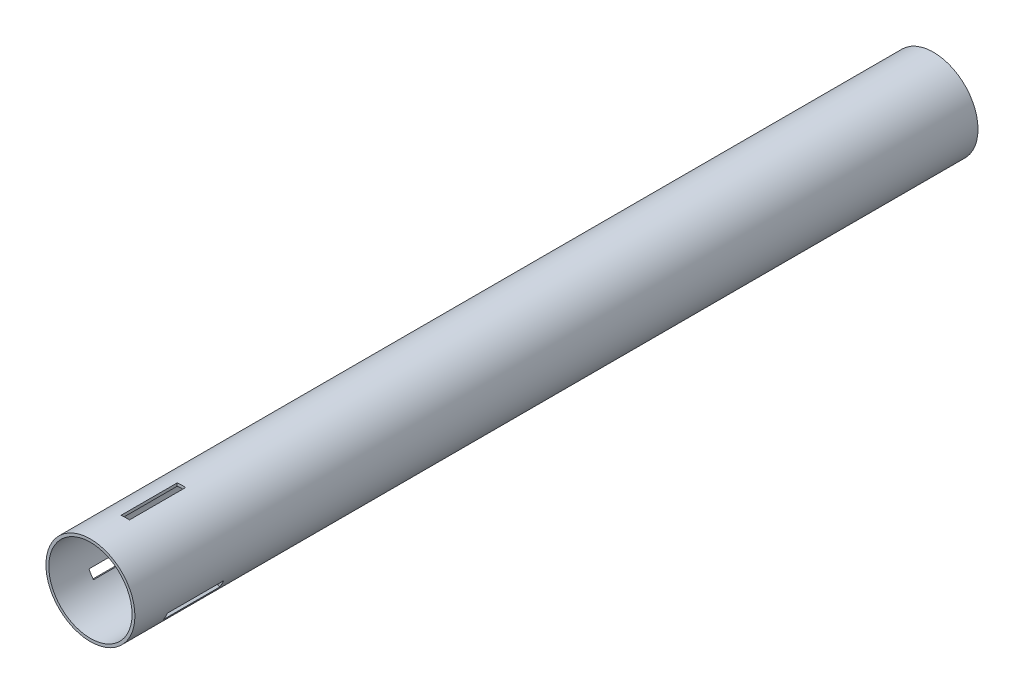
from build123d import *

# Parameters (mm, degrees)
SKETCH1_R           = 23.75
SKETCH1_R_2         = 22.225
BOSS_EXTRUDE1_DEPTH = 450
CUT_EXTRUDE1_START  = -77.970542
SKETCH2_W           = 4.52920266
SKETCH2_H           = 30
CUT_EXTRUDE1_DEPTH  = 1.720542
CIRPATTERN2_COUNT   = 3


with BuildPart() as part:
    # Sketch1 → Boss-Extrude1 (new body)
    with BuildSketch(Plane.XY):
        Circle(SKETCH1_R)
        Circle(SKETCH1_R_2, mode=Mode.SUBTRACT)
    extrude(amount=BOSS_EXTRUDE1_DEPTH)

    # Sketch2 → Cut-Extrude1 (cut)
    with BuildSketch(Plane(origin=(0, 100, 0), x_dir=(1, 0, 0), z_dir=(0, 1, 0)).offset(CUT_EXTRUDE1_START)):
        with Locations((-0.67710133, -415.7565327)):
            Rectangle(SKETCH2_W, SKETCH2_H)
    cut_extrude1 = extrude(amount=CUT_EXTRUDE1_DEPTH, mode=Mode.SUBTRACT)

    # CirPattern2: Cut-Extrude1 ×3 about axis
    cirpattern2_axis = Axis((0, 0, 0), (0, 0, 1))
    for i in range(1, CIRPATTERN2_COUNT):
        add(cut_extrude1.rotate(cirpattern2_axis, i * 360 / CIRPATTERN2_COUNT), mode=Mode.SUBTRACT)


solid = part.part
